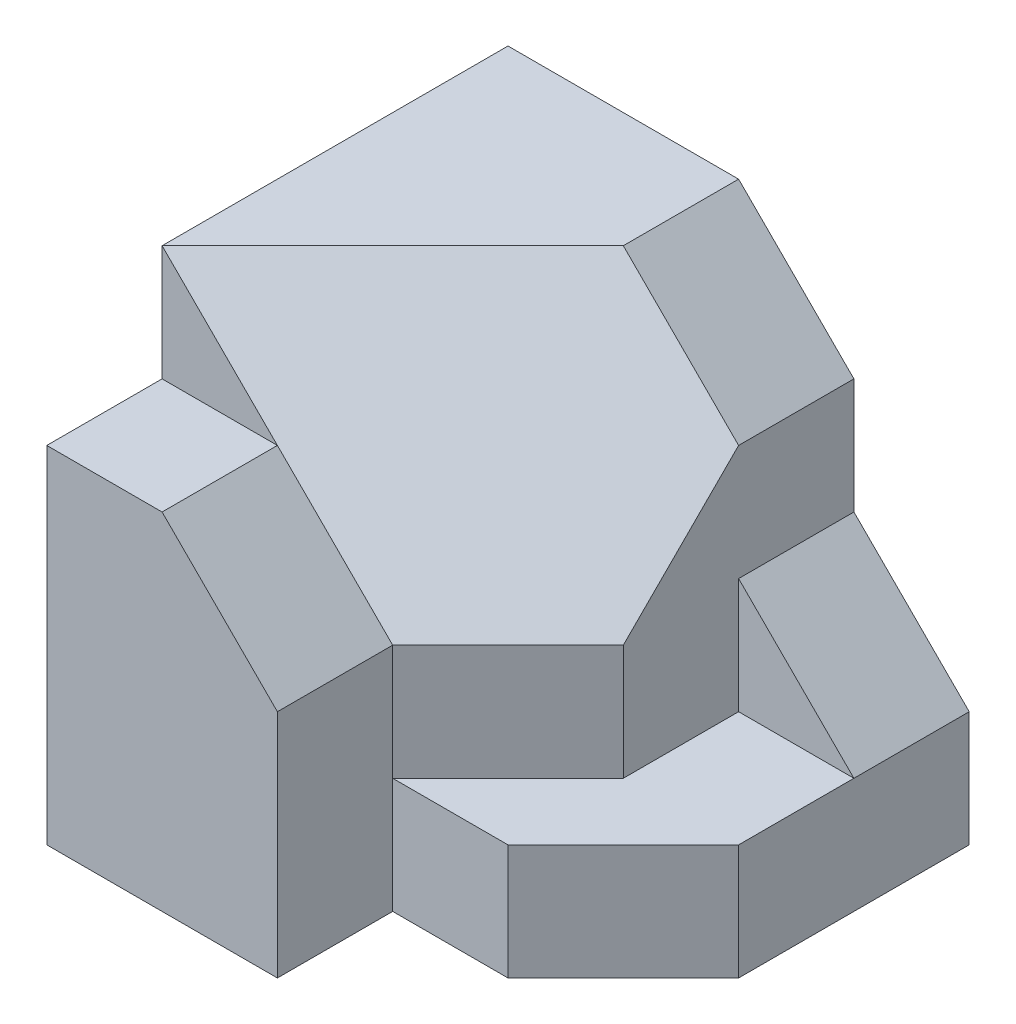
from build123d import *

# Parameters (mm, degrees)
BOSS_EXTRUDE1_DEPTH = 20
SKETCH2_W           = 5
SKETCH2_H           = 20
BOSS_EXTRUDE2_DEPTH = 5
CUT_EXTRUDE1_DEPTH  = 21
BOSS_EXTRUDE4_DEPTH = 20
CUT_EXTRUDE2_DEPTH  = 70
SKETCH5_W           = 5
SKETCH5_H           = 10
BOSS_EXTRUDE5_DEPTH = 5
CUT_EXTRUDE3_DEPTH  = 5
BOSS_EXTRUDE6_DEPTH = 5
BOSS_EXTRUDE7_DEPTH = 5


with BuildPart() as part:
    # Sketch1 → Boss-Extrude1 (new body)
    with BuildSketch(Plane(origin=(0, 0, 0), x_dir=(1, 0, 0), z_dir=(0, 1, 0))):
        Polygon((0, -15), (0, 0), (10, 0), (10, -5), align=None)
    extrude(amount=BOSS_EXTRUDE1_DEPTH)

    # Sketch2 → Boss-Extrude2 (add)
    with BuildSketch(Plane(origin=(10, 0, 0), x_dir=(0, 0, -1), z_dir=(1, 0, 0))):
        with Locations((-2.5, 10)):
            Rectangle(SKETCH2_W, SKETCH2_H)
    extrude(amount=BOSS_EXTRUDE2_DEPTH)

    # Sketch3 → Cut-Extrude1 (cut)
    with BuildSketch(Plane(origin=(0, 0, 0), x_dir=(-1, 0, 0), z_dir=(0, 0, -1))):
        Polygon((-10, 20), (-15, 20), (-15, 15), align=None)
    extrude(amount=-CUT_EXTRUDE1_DEPTH, mode=Mode.SUBTRACT)

    # Sketch4 → Boss-Extrude4 (add)
    with BuildSketch(Plane(origin=(0, 0, 0), x_dir=(-1, 0, 0), z_dir=(0, -1, 0))):
        Polygon((0, -15), (-10, -5), (-15, -5), (-15, -10), (-10, -15), align=None)
    extrude(amount=-BOSS_EXTRUDE4_DEPTH)

    # 3DSketch1 → Cut-Extrude2 (cut, along a direction that is not the sketch's normal)
    with BuildSketch(Plane(origin=(0, 20, 15), x_dir=(0.8017837257372734, -0.26726124191242434, -0.5345224838248487), z_dir=(-0.5773502691896257, -0.5773502691896256, -0.5773502691896261))):
        Polygon((0, 0), (13.363062096, -4.629100499), (18.708286934, 0), (17.371980724, 6.943650748), (10.690449676, 9.258200998), align=None)
    extrude(amount=-CUT_EXTRUDE2_DEPTH, dir=(-1, 0, 0), mode=Mode.SUBTRACT)

    # Sketch5 → Boss-Extrude5 (add)
    with BuildSketch(Plane(origin=(15, 0, 0), x_dir=(0, 0, -1), z_dir=(1, 0, 0))):
        with Locations((-2.5, 5)):
            Rectangle(SKETCH5_W, SKETCH5_H)
    extrude(amount=BOSS_EXTRUDE5_DEPTH)

    # Sketch6 → Cut-Extrude3 (cut)
    with BuildSketch(Plane.XY.offset(5)):
        Polygon((15, 10), (20, 5), (20, 10), align=None)
    extrude(amount=-CUT_EXTRUDE3_DEPTH, mode=Mode.SUBTRACT)

    # Sketch7 → Boss-Extrude6 (add)
    with BuildSketch(Plane(origin=(0, 0, 0), x_dir=(-1, 0, 0), z_dir=(0, -1, 0))):
        Polygon((-15, -10), (-15, -5), (-20, -5), (-20, -10), (-15, -15), (-10, -15), align=None)
    extrude(amount=-BOSS_EXTRUDE6_DEPTH)

    # Sketch8 → Boss-Extrude7 (add)
    with BuildSketch(Plane.XY.offset(15)):
        Polygon((0, 15), (5, 15), (10, 10), (10, 0), (0, 0), align=None)
    extrude(amount=BOSS_EXTRUDE7_DEPTH)


solid = part.part
